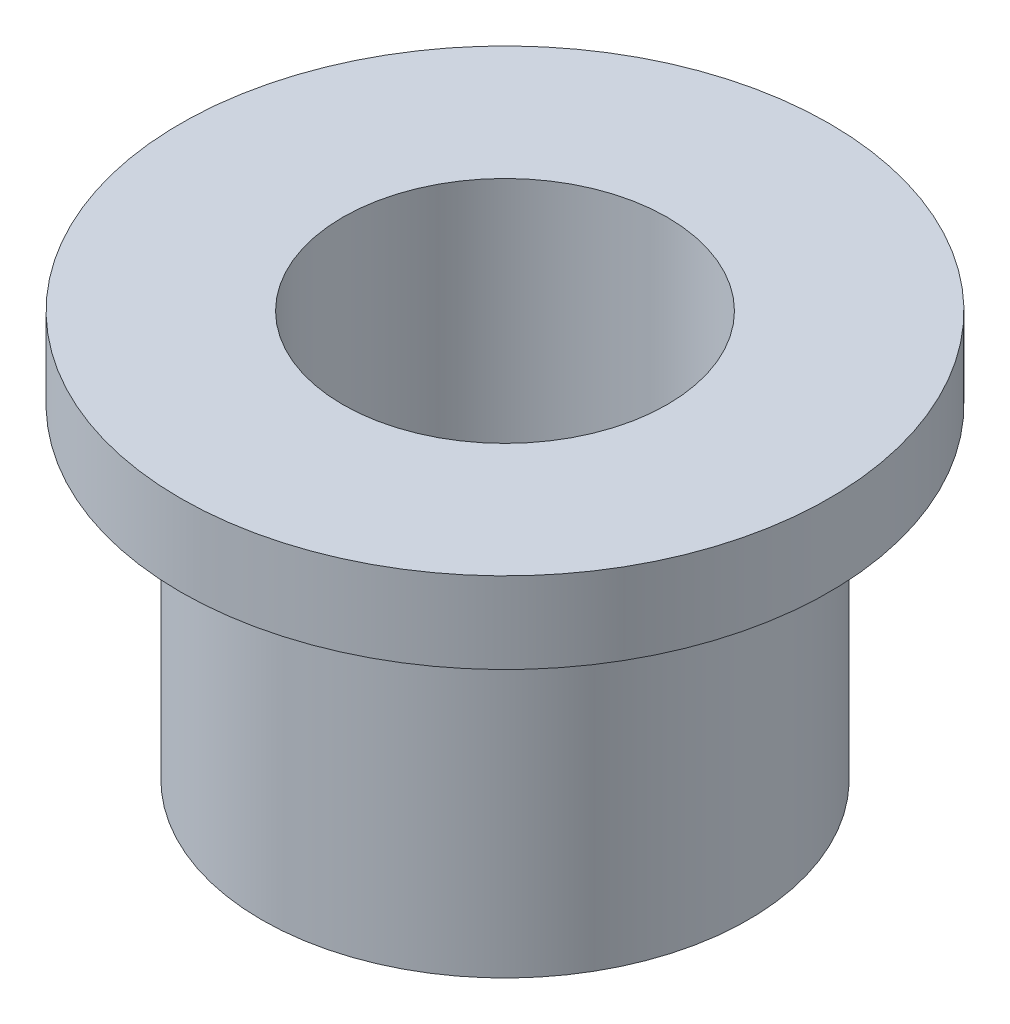
from build123d import *


with BuildPart() as part:
    # Sketch1 → Revolve1 (revolve)
    with BuildSketch(Plane(origin=(0, 0, 0), x_dir=(0, 0, -1), z_dir=(1, 0, 0))):
        Polygon((3.175, 0), (3.175, 7.9375), (6.35, 7.9375), (6.35, 6.35), (4.7625, 6.35), (4.7625, 0), align=None)
    revolve(axis=Axis((0, 0, 0), (0, 1, 0)))


solid = part.part
